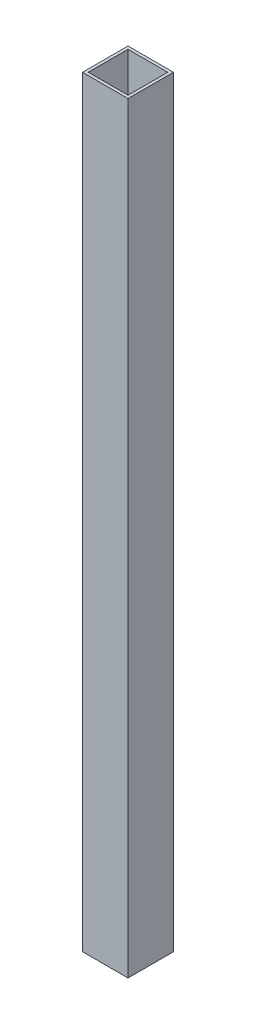
from build123d import *

# Parameters (mm, degrees)
SKETCH1_W           = 50.8
SKETCH1_H           = 50.8
SKETCH1_W_2         = 44.45
SKETCH1_H_2         = 44.45
BOSS_EXTRUDE1_DEPTH = 850.900199


with BuildPart() as part:
    # Sketch1 → Boss-Extrude1 (new body)
    with BuildSketch(Plane(origin=(0, 0, 0), x_dir=(1, 0, 0), z_dir=(0, 1, 0))):
        Rectangle(SKETCH1_W, SKETCH1_H)
        Rectangle(SKETCH1_W_2, SKETCH1_H_2, mode=Mode.SUBTRACT)
    extrude(amount=BOSS_EXTRUDE1_DEPTH)


solid = part.part
